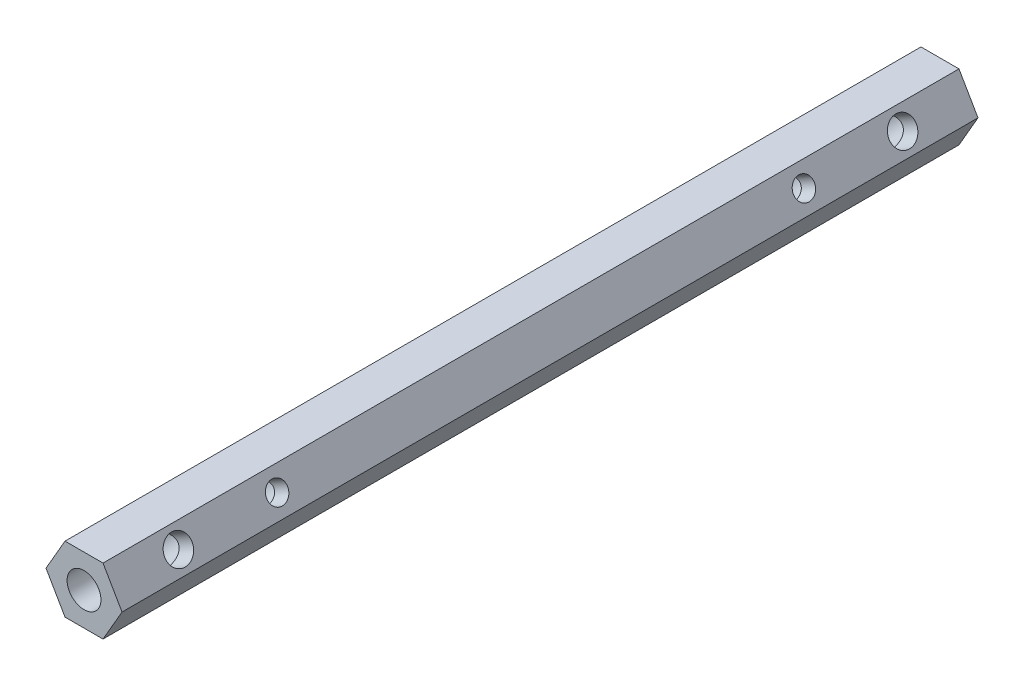
from build123d import *

# Parameters (mm, degrees)
SKETCH1_R           = 3.2639
BOSS_EXTRUDE1_DEPTH = 165.1
SKETCH2_R           = 2.0193
SKETCH2_R_2         = 2.6289
CUT_EXTRUDE1_DEPTH  = 16.875


with BuildPart() as part:
    # Sketch1 → Boss-Extrude1 (new body)
    with BuildSketch(Plane.XY):
        Polygon((-3.666174209, 6.35), (-7.332348419, 0), (-3.666174209, -6.35), (3.666174209, -6.35), (7.332348419, 0), (3.666174209, 6.35), align=None)
        Circle(SKETCH1_R, mode=Mode.SUBTRACT)
    extrude(amount=BOSS_EXTRUDE1_DEPTH)

    # Sketch2 → Cut-Extrude1 (cut, through all)
    with BuildSketch(Plane(origin=(5.499261314, 3.175, 0), x_dir=(0, 0, -1), z_dir=(0.866025404, 0.5, 0))):
        with Locations((-31.75, 0)):
            Circle(SKETCH2_R)
        with Locations((-133.35, 0)):
            Circle(SKETCH2_R)
        with Locations((-12.7, 0)):
            Circle(SKETCH2_R_2)
        with Locations((-152.4, 0)):
            Circle(SKETCH2_R_2)
    extrude(amount=-CUT_EXTRUDE1_DEPTH, mode=Mode.SUBTRACT)


solid = part.part
